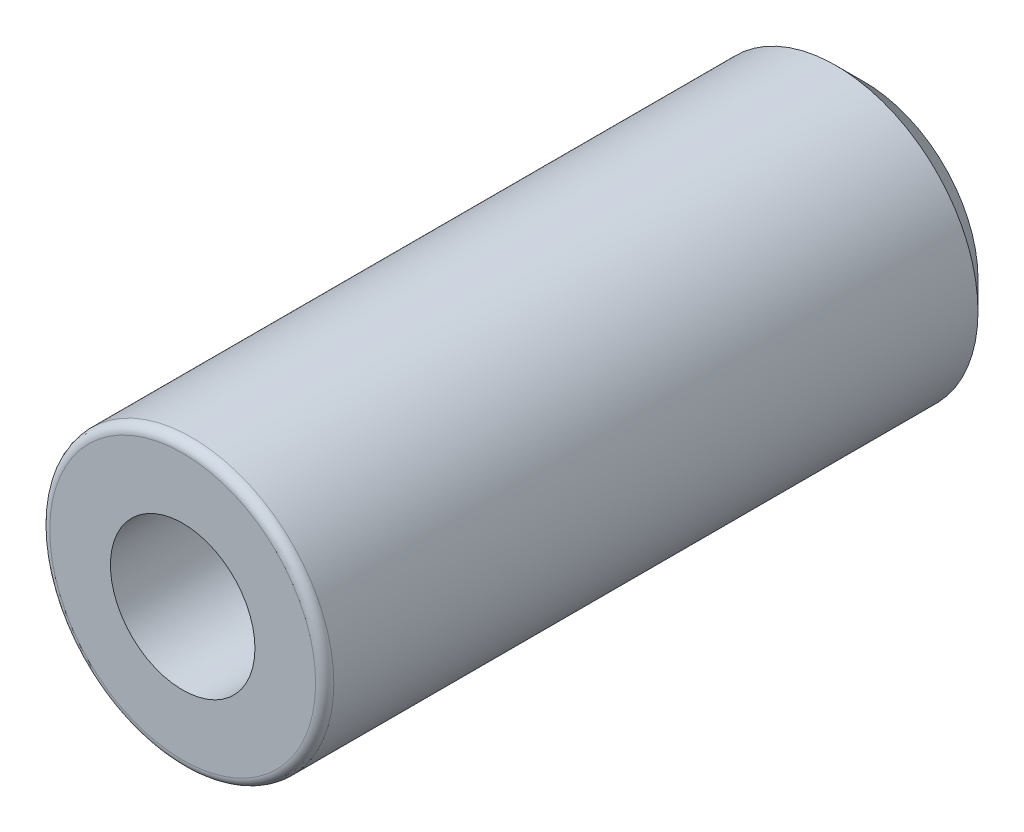
from build123d import *

# Parameters (mm, degrees)
SKETCH1_R                  = 3.96875
EXTRUDE1_DEPTH             = 9.525
FILLET1_R                  = 0.254
CHAMFER1_SIZE              = 0.79375
F_10_32_TAPPED_HOLE1_D     = 4.0386
F_10_32_TAPPED_HOLE1_DEPTH = 12.0396
F_10_32_TAPPED_HOLE1_TIP   = 1.213317848


with BuildPart() as part:
    # Sketch1 → Extrude1 (new body, symmetric)
    with BuildSketch(Plane.XY):
        Circle(SKETCH1_R)
    extrude(amount=EXTRUDE1_DEPTH, both=True)

    # Fillet1
    fillet1_edges = [part.edges().sort_by_distance(p)[0] for p in [
        (-3.96875, 0, 9.525),
    ]]
    fillet(fillet1_edges, radius=FILLET1_R)

    # Chamfer1
    chamfer1_edges = [part.edges().sort_by_distance(p)[0] for p in [
        (-3.96875, 0, -9.525),
    ]]
    chamfer(chamfer1_edges, length=CHAMFER1_SIZE)

    # #10-32 Tapped Hole1
    with Locations(Plane.XY.offset(9.525)):
        with Locations((0, 0)):
            Hole(F_10_32_TAPPED_HOLE1_D / 2, depth=F_10_32_TAPPED_HOLE1_DEPTH)
            with Locations((0, 0, -(F_10_32_TAPPED_HOLE1_DEPTH + F_10_32_TAPPED_HOLE1_TIP / 2))):  # 118° drill point
                Cone(0, F_10_32_TAPPED_HOLE1_D / 2, F_10_32_TAPPED_HOLE1_TIP, mode=Mode.SUBTRACT)


solid = part.part
